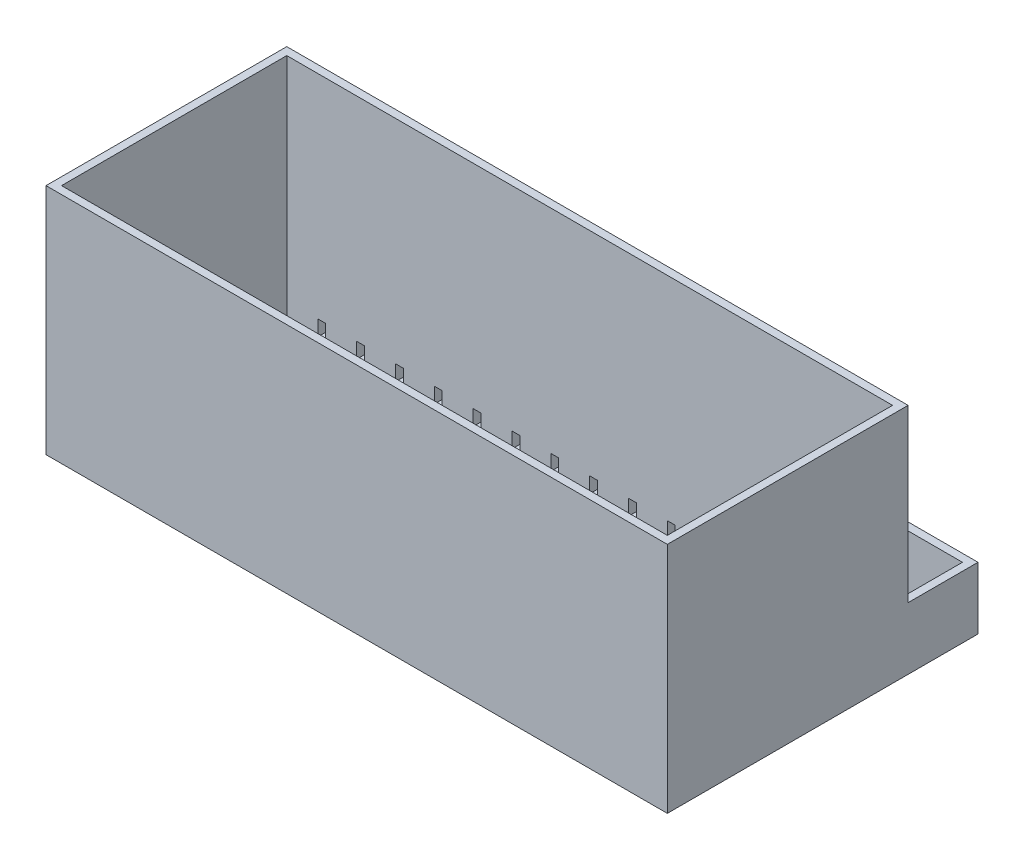
from build123d import *

# Parameters (mm, degrees)
SKETCH1_W           = 195
SKETCH1_H           = 95
BOSS_EXTRUDE1_DEPTH = 1.6
SKETCH1_5_W         = 7.5
SKETCH1_5_H         = 2.5
SKETCH1_5_W_2       = 2.5
SKETCH1_5_W_3       = 10
BOSS_EXTRUDE2_DEPTH = 75
BOSS_EXTRUDE3_DEPTH = 20
CUT_EXTRUDE1_START  = 1.6
SKETCH1_7_W         = 2.5
SKETCH1_7_H         = 2.5
CUT_EXTRUDE1_DEPTH  = 5


with BuildPart() as part:
    # Sketch1 → Boss-Extrude1 (new body)
    with BuildSketch(Plane(origin=(0, 0, 0), x_dir=(1, 0, 0), z_dir=(0, 1, 0))):
        with Locations((100, 50)):
            Rectangle(SKETCH1_W, SKETCH1_H)
    extrude(amount=BOSS_EXTRUDE1_DEPTH)

    # Sketch1_5 → Boss-Extrude2 (add)
    with BuildSketch(Plane(origin=(0, 0, 0), x_dir=(1, 0, 0), z_dir=(0, 1, 0))):
        Polygon((0, 0), (100, 0), (100, 2.5), (2.5, 2.5), (2.5, 75), (2.5, 77.5), (0, 77.5), align=None)
        Polygon((100, 2.5), (100, 0), (200, 0), (200, 77.5), (197.5, 77.5), (197.5, 75), (197.5, 2.5), align=None)
        with Locations((193.75, 76.25)):
            Rectangle(SKETCH1_5_W, SKETCH1_5_H)
        with Locations((188.75, 76.25)):
            Rectangle(SKETCH1_5_W_2, SKETCH1_5_H)
        with Locations((182.5, 76.25)):
            Rectangle(SKETCH1_5_W_3, SKETCH1_5_H)
        with Locations((176.25, 76.25)):
            Rectangle(SKETCH1_5_W_2, SKETCH1_5_H)
        with Locations((170, 76.25)):
            Rectangle(SKETCH1_5_W_3, SKETCH1_5_H)
        with Locations((163.75, 76.25)):
            Rectangle(SKETCH1_5_W_2, SKETCH1_5_H)
        with Locations((157.5, 76.25)):
            Rectangle(SKETCH1_5_W_3, SKETCH1_5_H)
        with Locations((151.25, 76.25)):
            Rectangle(SKETCH1_5_W_2, SKETCH1_5_H)
        with Locations((145, 76.25)):
            Rectangle(SKETCH1_5_W_3, SKETCH1_5_H)
        with Locations((138.75, 76.25)):
            Rectangle(SKETCH1_5_W_2, SKETCH1_5_H)
        with Locations((132.5, 76.25)):
            Rectangle(SKETCH1_5_W_3, SKETCH1_5_H)
        with Locations((126.25, 76.25)):
            Rectangle(SKETCH1_5_W_2, SKETCH1_5_H)
        with Locations((120, 76.25)):
            Rectangle(SKETCH1_5_W_3, SKETCH1_5_H)
        with Locations((113.75, 76.25)):
            Rectangle(SKETCH1_5_W_2, SKETCH1_5_H)
        with Locations((107.5, 76.25)):
            Rectangle(SKETCH1_5_W_3, SKETCH1_5_H)
        with Locations((101.25, 76.25)):
            Rectangle(SKETCH1_5_W_2, SKETCH1_5_H)
        with Locations((95, 76.25)):
            Rectangle(SKETCH1_5_W_3, SKETCH1_5_H)
        with Locations((88.75, 76.25)):
            Rectangle(SKETCH1_5_W_2, SKETCH1_5_H)
        with Locations((82.5, 76.25)):
            Rectangle(SKETCH1_5_W_3, SKETCH1_5_H)
        with Locations((76.25, 76.25)):
            Rectangle(SKETCH1_5_W_2, SKETCH1_5_H)
        with Locations((70, 76.25)):
            Rectangle(SKETCH1_5_W_3, SKETCH1_5_H)
        with Locations((63.75, 76.25)):
            Rectangle(SKETCH1_5_W_2, SKETCH1_5_H)
        with Locations((57.5, 76.25)):
            Rectangle(SKETCH1_5_W_3, SKETCH1_5_H)
        with Locations((51.25, 76.25)):
            Rectangle(SKETCH1_5_W_2, SKETCH1_5_H)
        with Locations((45, 76.25)):
            Rectangle(SKETCH1_5_W_3, SKETCH1_5_H)
        with Locations((38.75, 76.25)):
            Rectangle(SKETCH1_5_W_2, SKETCH1_5_H)
        with Locations((32.5, 76.25)):
            Rectangle(SKETCH1_5_W_3, SKETCH1_5_H)
        with Locations((26.25, 76.25)):
            Rectangle(SKETCH1_5_W_2, SKETCH1_5_H)
        with Locations((20, 76.25)):
            Rectangle(SKETCH1_5_W_3, SKETCH1_5_H)
        with Locations((13.75, 76.25)):
            Rectangle(SKETCH1_5_W_2, SKETCH1_5_H)
        with Locations((7.5, 76.25)):
            Rectangle(SKETCH1_5_W_3, SKETCH1_5_H)
    extrude(amount=BOSS_EXTRUDE2_DEPTH)

    # Sketch1_6 → Boss-Extrude3 (add)
    with BuildSketch(Plane(origin=(0, 0, 0), x_dir=(1, 0, 0), z_dir=(0, 1, 0))):
        Polygon((0, 100), (0, 77.5), (2.5, 77.5), (2.5, 97.5), (197.5, 97.5), (197.5, 77.5), (200, 77.5), (200, 100), align=None)
    extrude(amount=BOSS_EXTRUDE3_DEPTH)

    # Sketch1_7 → Cut-Extrude1 (cut)
    with BuildSketch(Plane(origin=(0, 0, 0), x_dir=(1, 0, 0), z_dir=(0, 1, 0)).offset(CUT_EXTRUDE1_START)):
        with Locations((188.75, 76.25)):
            Rectangle(SKETCH1_7_W, SKETCH1_7_H)
        with Locations((176.25, 76.25)):
            Rectangle(SKETCH1_7_W, SKETCH1_7_H)
        with Locations((163.75, 76.25)):
            Rectangle(SKETCH1_7_W, SKETCH1_7_H)
        with Locations((151.25, 76.25)):
            Rectangle(SKETCH1_7_W, SKETCH1_7_H)
        with Locations((138.75, 76.25)):
            Rectangle(SKETCH1_7_W, SKETCH1_7_H)
        with Locations((126.25, 76.25)):
            Rectangle(SKETCH1_7_W, SKETCH1_7_H)
        with Locations((113.75, 76.25)):
            Rectangle(SKETCH1_7_W, SKETCH1_7_H)
        with Locations((101.25, 76.25)):
            Rectangle(SKETCH1_7_W, SKETCH1_7_H)
        with Locations((88.75, 76.25)):
            Rectangle(SKETCH1_7_W, SKETCH1_7_H)
        with Locations((76.25, 76.25)):
            Rectangle(SKETCH1_7_W, SKETCH1_7_H)
        with Locations((63.75, 76.25)):
            Rectangle(SKETCH1_7_W, SKETCH1_7_H)
        with Locations((51.25, 76.25)):
            Rectangle(SKETCH1_7_W, SKETCH1_7_H)
        with Locations((38.75, 76.25)):
            Rectangle(SKETCH1_7_W, SKETCH1_7_H)
        with Locations((26.25, 76.25)):
            Rectangle(SKETCH1_7_W, SKETCH1_7_H)
        with Locations((13.75, 76.25)):
            Rectangle(SKETCH1_7_W, SKETCH1_7_H)
    extrude(amount=CUT_EXTRUDE1_DEPTH, mode=Mode.SUBTRACT)


solid = part.part
